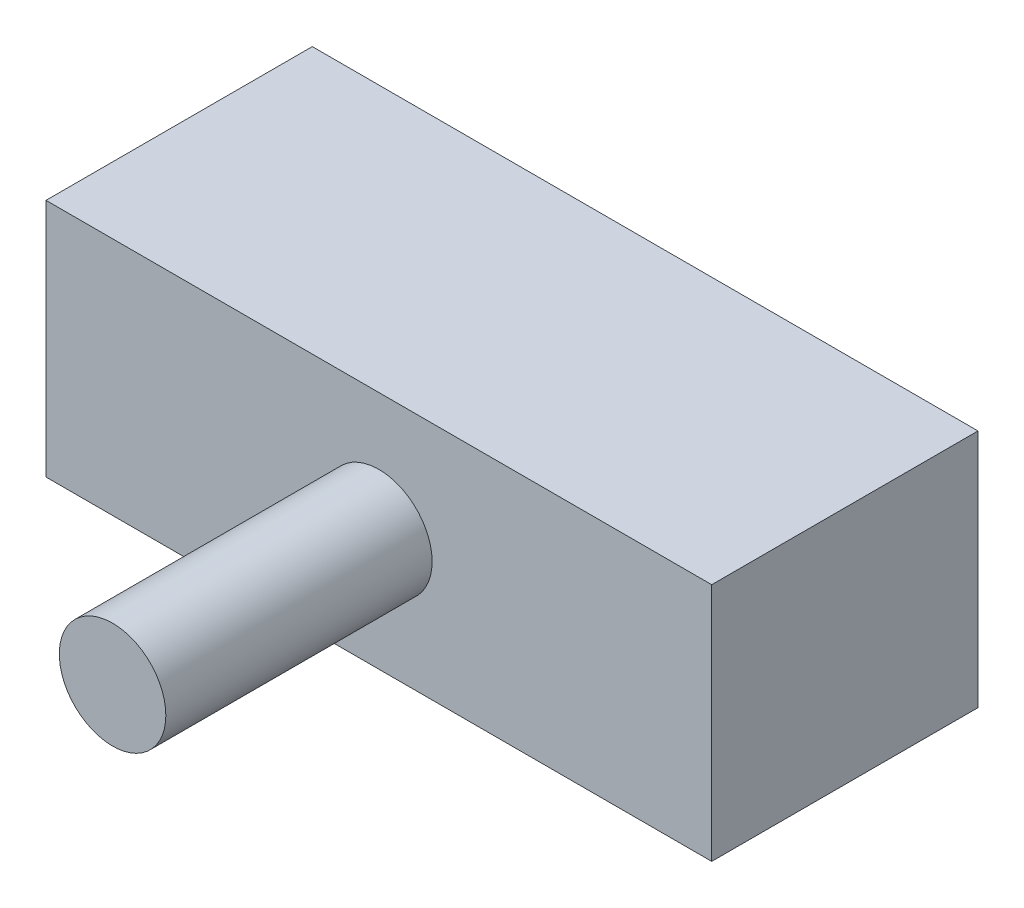
from build123d import *

# Parameters (mm, degrees)
SKETCH1_W           = 25
SKETCH1_H           = 9
BOSS_EXTRUDE1_DEPTH = 10
SKETCH2_R           = 2
BOSS_EXTRUDE2_DEPTH = 10


with BuildPart() as part:
    # Sketch1 → Boss-Extrude1 (new body)
    with BuildSketch(Plane.XY):
        Rectangle(SKETCH1_W, SKETCH1_H)
    extrude(amount=BOSS_EXTRUDE1_DEPTH)

    # Sketch2 → Boss-Extrude2 (add)
    with BuildSketch(Plane.XY.offset(10)):
        Circle(SKETCH2_R)
    extrude(amount=BOSS_EXTRUDE2_DEPTH)


solid = part.part
